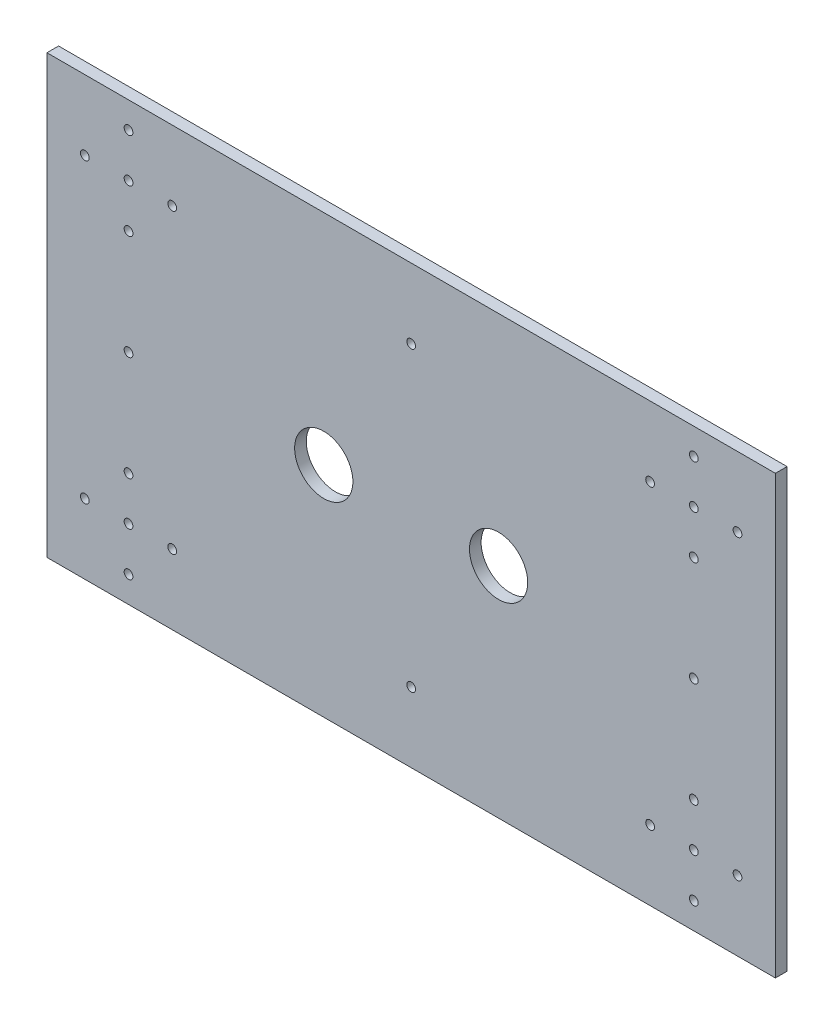
from build123d import *

# Parameters (mm, degrees)
SKETCH1_W           = 250
SKETCH1_H           = 150
SKETCH1_R           = 1.5
SKETCH1_R_2         = 10
BOSS_EXTRUDE1_DEPTH = 4


with BuildPart() as part:
    # Sketch1 → Boss-Extrude1 (new body)
    with BuildSketch(Plane.XY):
        with Locations((64.901502586, -41.133333333)):
            Rectangle(SKETCH1_W, SKETCH1_H)
        with Locations((-32.098497414, -92.133333333)):
            Circle(SKETCH1_R, mode=Mode.SUBTRACT)
        with Locations((-17.098497414, -92.133333333)):
            Circle(SKETCH1_R, mode=Mode.SUBTRACT)
        with Locations((-32.098497414, -107.133333333)):
            Circle(SKETCH1_R, mode=Mode.SUBTRACT)
        with Locations((-47.098497414, -92.133333333)):
            Circle(SKETCH1_R, mode=Mode.SUBTRACT)
        with Locations((-32.098497414, -77.133333333)):
            Circle(SKETCH1_R, mode=Mode.SUBTRACT)
        with Locations((176.901502586, -92.133333333)):
            Circle(SKETCH1_R, mode=Mode.SUBTRACT)
        with Locations((161.901502586, -92.133333333)):
            Circle(SKETCH1_R, mode=Mode.SUBTRACT)
        with Locations((161.901502586, -77.133333333)):
            Circle(SKETCH1_R, mode=Mode.SUBTRACT)
        with Locations((146.901502586, -92.133333333)):
            Circle(SKETCH1_R, mode=Mode.SUBTRACT)
        with Locations((161.901502586, -107.133333333)):
            Circle(SKETCH1_R, mode=Mode.SUBTRACT)
        with Locations((176.901502586, 9.866666667)):
            Circle(SKETCH1_R, mode=Mode.SUBTRACT)
        with Locations((161.901502586, 9.866666667)):
            Circle(SKETCH1_R, mode=Mode.SUBTRACT)
        with Locations((161.901502586, 24.866666667)):
            Circle(SKETCH1_R, mode=Mode.SUBTRACT)
        with Locations((146.901502586, 9.866666667)):
            Circle(SKETCH1_R, mode=Mode.SUBTRACT)
        with Locations((161.901502586, -5.133333333)):
            Circle(SKETCH1_R, mode=Mode.SUBTRACT)
        with Locations((-17.098497414, 9.866666667)):
            Circle(SKETCH1_R, mode=Mode.SUBTRACT)
        with Locations((-32.098497414, 9.866666667)):
            Circle(SKETCH1_R, mode=Mode.SUBTRACT)
        with Locations((-32.098497414, 24.866666667)):
            Circle(SKETCH1_R, mode=Mode.SUBTRACT)
        with Locations((-47.098497414, 9.866666667)):
            Circle(SKETCH1_R, mode=Mode.SUBTRACT)
        with Locations((-32.098497414, -5.133333333)):
            Circle(SKETCH1_R, mode=Mode.SUBTRACT)
        with Locations((-32.098497414, -41.133333333)):
            Circle(SKETCH1_R, mode=Mode.SUBTRACT)
        with Locations((161.901502586, -41.133333333)):
            Circle(SKETCH1_R, mode=Mode.SUBTRACT)
        with Locations((64.901502586, 9.866666667)):
            Circle(SKETCH1_R, mode=Mode.SUBTRACT)
        with Locations((64.901502586, -92.133333333)):
            Circle(SKETCH1_R, mode=Mode.SUBTRACT)
        with Locations((94.901502586, -41.133333333)):
            Circle(SKETCH1_R_2, mode=Mode.SUBTRACT)
        with Locations((34.901502586, -41.133333333)):
            Circle(SKETCH1_R_2, mode=Mode.SUBTRACT)
    extrude(amount=BOSS_EXTRUDE1_DEPTH)


solid = part.part
